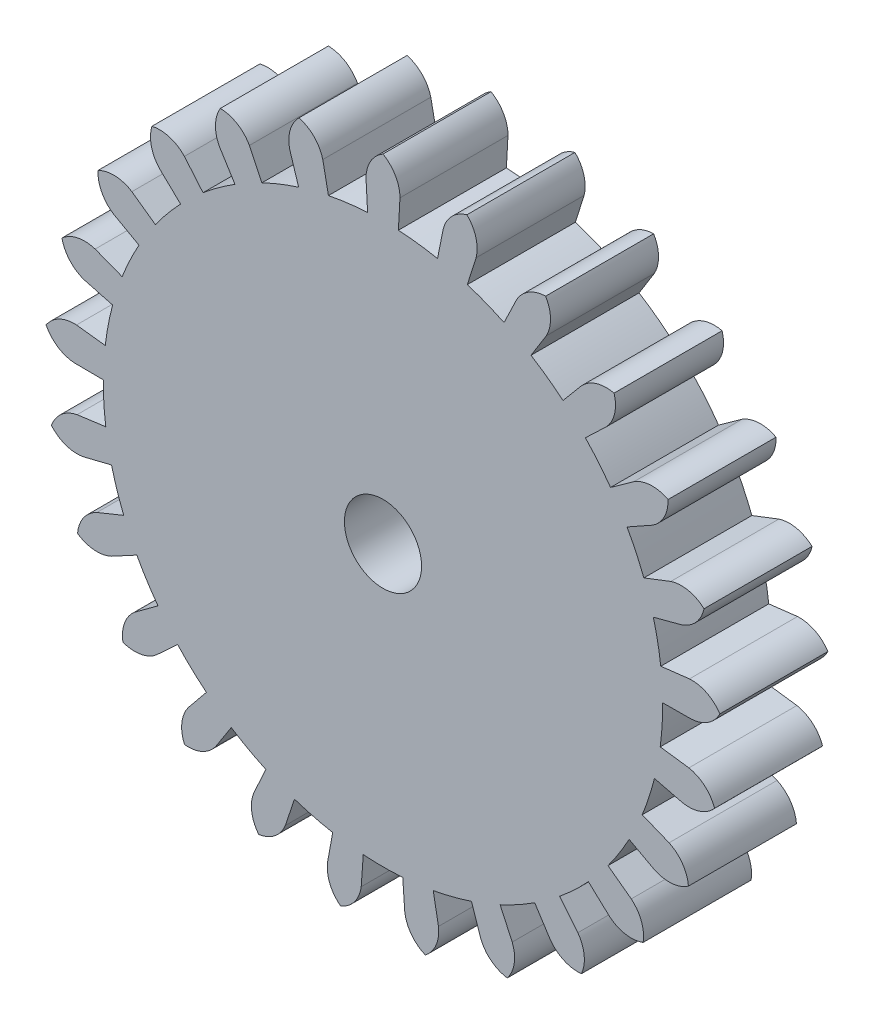
from build123d import *

# Parameters (mm, degrees)
SKETCH1_R           = 9.062508511
BOSS_EXTRUDE1_DEPTH = 3.5
CIRPATTERN1_COUNT   = 25
SKETCH3_R           = 4
BOSS_EXTRUDE2_DEPTH = 2
SKETCH2_R           = 1.25
CUT_EXTRUDE1_DEPTH  = 6.5


with BuildPart() as part:
    # Sketch1 → Boss-Extrude1 (new body)
    with BuildSketch(Plane.XY):
        with BuildLine():
            ThreePointArc((0, -29.062508511), (-0.402627944, -29.465136456), (-0.55, -30.015136456))
            Line((-0.55, -30.015136456), (-0.498437968, -30.951208914))
            ThreePointArc((-0.498437968, -30.951208914), (0, -30.937491489), (0.498437968, -30.951208914))
            Line((0.498437968, -30.951208914), (0.55, -30.015136456))
            ThreePointArc((0.55, -30.015136456), (0.402627944, -29.465136456), (0, -29.062508511))
        make_face()
        with Locations((0, -40)):
            Circle(SKETCH1_R)
    boss_extrude1 = extrude(amount=BOSS_EXTRUDE1_DEPTH)

    # CirPattern1: Boss-Extrude1 ×25 about axis
    cirpattern1_axis = Axis((0, -40, 0), (0, 0, 1))
    for i in range(1, CIRPATTERN1_COUNT):
        add(boss_extrude1.rotate(cirpattern1_axis, i * 360 / CIRPATTERN1_COUNT))

    # Sketch3 → Boss-Extrude2 (add)
    with BuildSketch(Plane(origin=(0, 0, 0), x_dir=(-1, 0, 0), z_dir=(0, 0, -1))):
        with Locations((0, -40)):
            Circle(SKETCH3_R)
    extrude(amount=BOSS_EXTRUDE2_DEPTH)

    # Sketch2 → Cut-Extrude1 (cut, through all)
    with BuildSketch(Plane.XY.offset(3.5)):
        with Locations((0, -40)):
            Circle(SKETCH2_R)
    extrude(amount=-CUT_EXTRUDE1_DEPTH, mode=Mode.SUBTRACT)


solid = part.part
